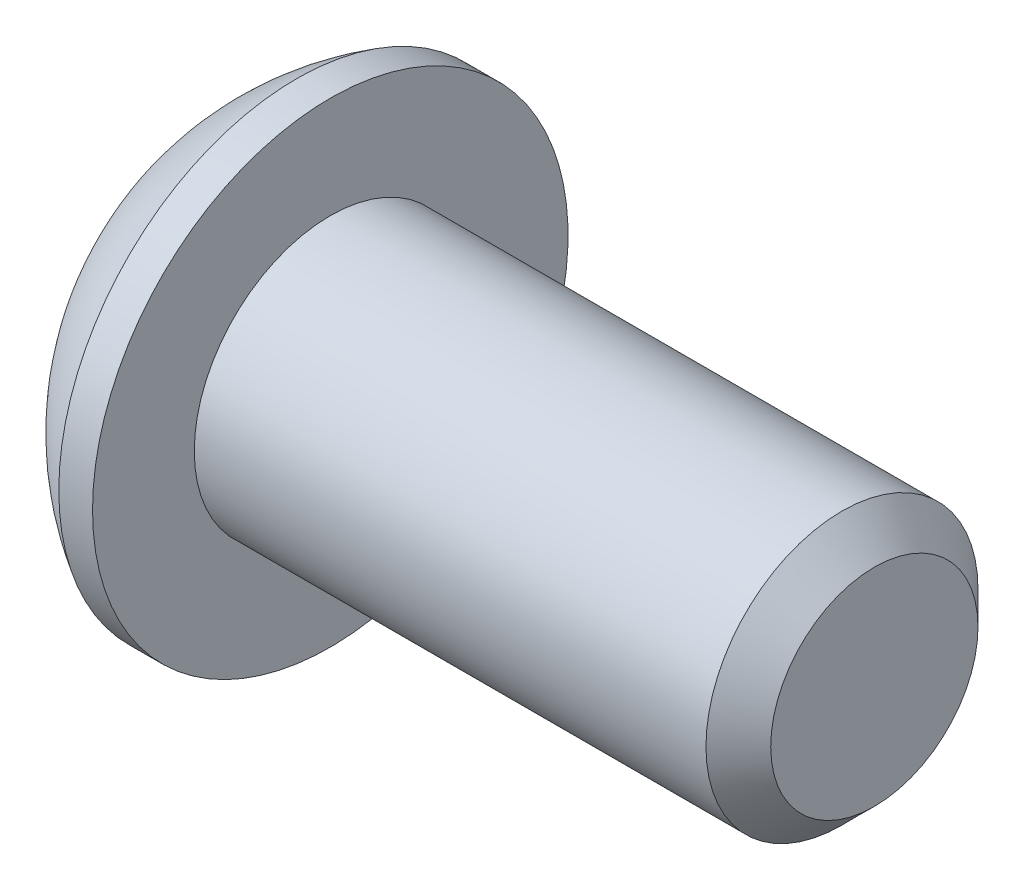
from build123d import *

# Parameters (mm, degrees)
HEX_2_DEPTH = 2.2098


with BuildPart() as part:
    # BodySke → BaseBody (revolve)
    with BuildSketch(Plane.XY):
        with BuildLine():
            Line((16.0528, 0), (16.0528, 2.41935))
            Line((16.0528, 2.41935), (15.29715, 3.175))
            Line((15.29715, 3.175), (3.3528, 3.175))
            Line((3.3528, 3.175), (3.3528, 5.5499))
            Line((3.3528, 5.5499), (2.5654, 5.5499))
            ThreePointArc((2.5654, 5.5499), (1.073764503, 4.355582759), (0, 2.77495))
            Line((0, 2.77495), (0, 0))
            Line((0, 0), (16.0528, 0))
        make_face()
    revolve(axis=Axis((0, 0, 0), (1, 0, 0)))

    # Sketch2 → PreBroach (revolve, cut)
    with BuildSketch(Plane.XY):
        Polygon((0, 1.9812), (2.2098, 1.9812), (3.353646353, 0), (0, 0), align=None)
    revolve(axis=Axis((0, 0, 0), (1, 0, 0)), mode=Mode.SUBTRACT)

    # Sketch3 → Hex 2 (cut)
    with BuildSketch(Plane(origin=(0, 0, 0), x_dir=(0, 0, -1), z_dir=(1, 0, 0))):
        Polygon((-1.9812, -1.143846353), (-1.9812, 1.143846353), (0, 2.287692707), (1.9812, 1.143846353), (1.9812, -1.143846353), (0, -2.287692707), align=None)
    extrude(amount=HEX_2_DEPTH, mode=Mode.SUBTRACT)


solid = part.part
